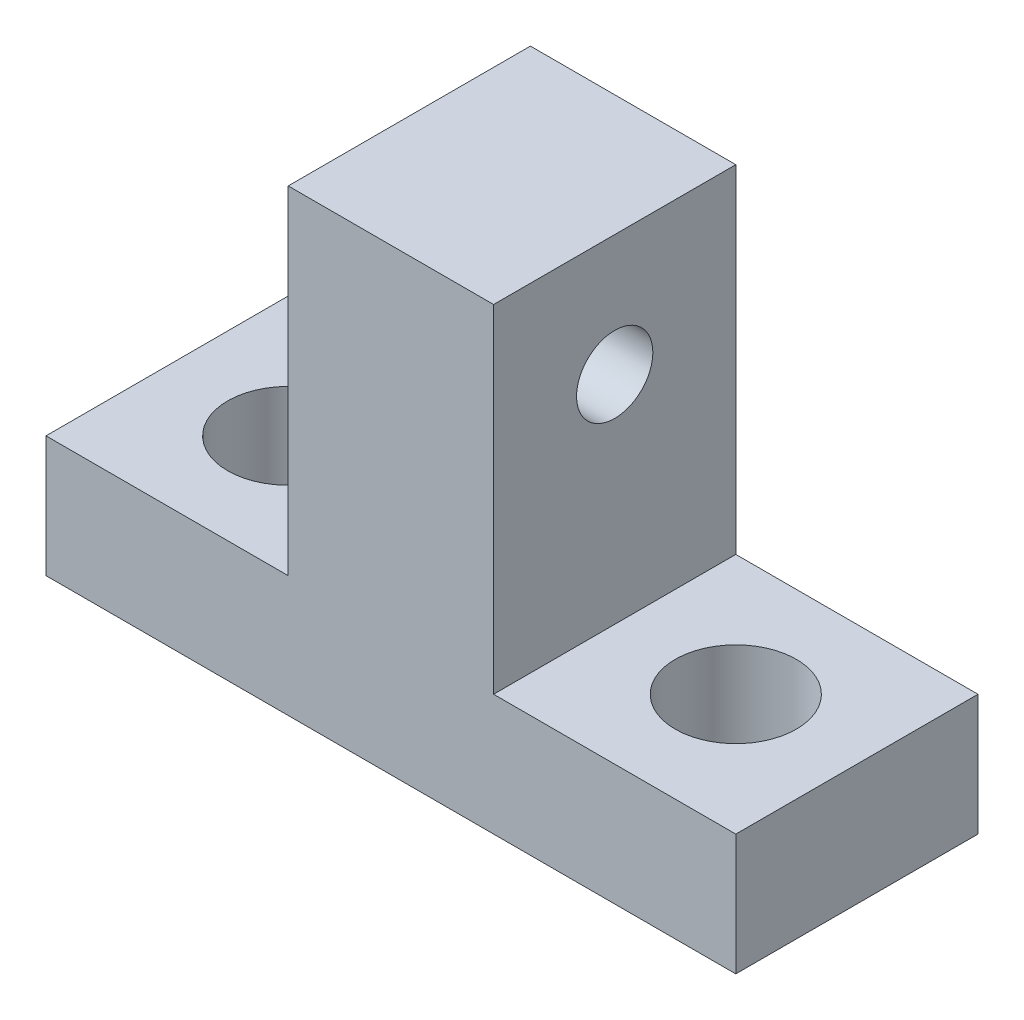
from build123d import *

# Parameters (mm, degrees)
SKETCH1_W           = 10.7696
SKETCH1_H           = 17.699
BOSS_EXTRUDE1_DEPTH = 12.7
SKETCH5_R           = 2
CUT_EXTRUDE2_DEPTH  = 24.4696
SKETCH6_R           = 3.175
CUT_EXTRUDE3_DEPTH  = 7.35


with BuildPart() as part:
    # Sketch1 → Boss-Extrude1 (new body)
    with BuildSketch(Plane.XY):
        Polygon((18.0848, -8.8495), (5.3848, -8.8495), (-5.3848, -8.8495), (-18.0848, -8.8495), (-18.0848, -15.1995), (18.0848, -15.1995), align=None)
        Rectangle(SKETCH1_W, SKETCH1_H)
    extrude(amount=BOSS_EXTRUDE1_DEPTH)

    # Sketch5 → Cut-Extrude2 (cut, through all)
    with BuildSketch(Plane(origin=(5.3848, 0, 0), x_dir=(0, 0, -1), z_dir=(1, 0, 0))):
        with Locations((-6.35, 2.4995)):
            Circle(SKETCH5_R)
    extrude(amount=-CUT_EXTRUDE2_DEPTH, mode=Mode.SUBTRACT)

    # Sketch6 → Cut-Extrude3 (cut, through all)
    with BuildSketch(Plane(origin=(0, -8.8495, 0), x_dir=(1, 0, 0), z_dir=(0, 1, 0))):
        with Locations((-11.7348, -6.35)):
            Circle(SKETCH6_R)
        with Locations((11.7348, -6.35)):
            Circle(SKETCH6_R)
    extrude(amount=-CUT_EXTRUDE3_DEPTH, mode=Mode.SUBTRACT)


solid = part.part
